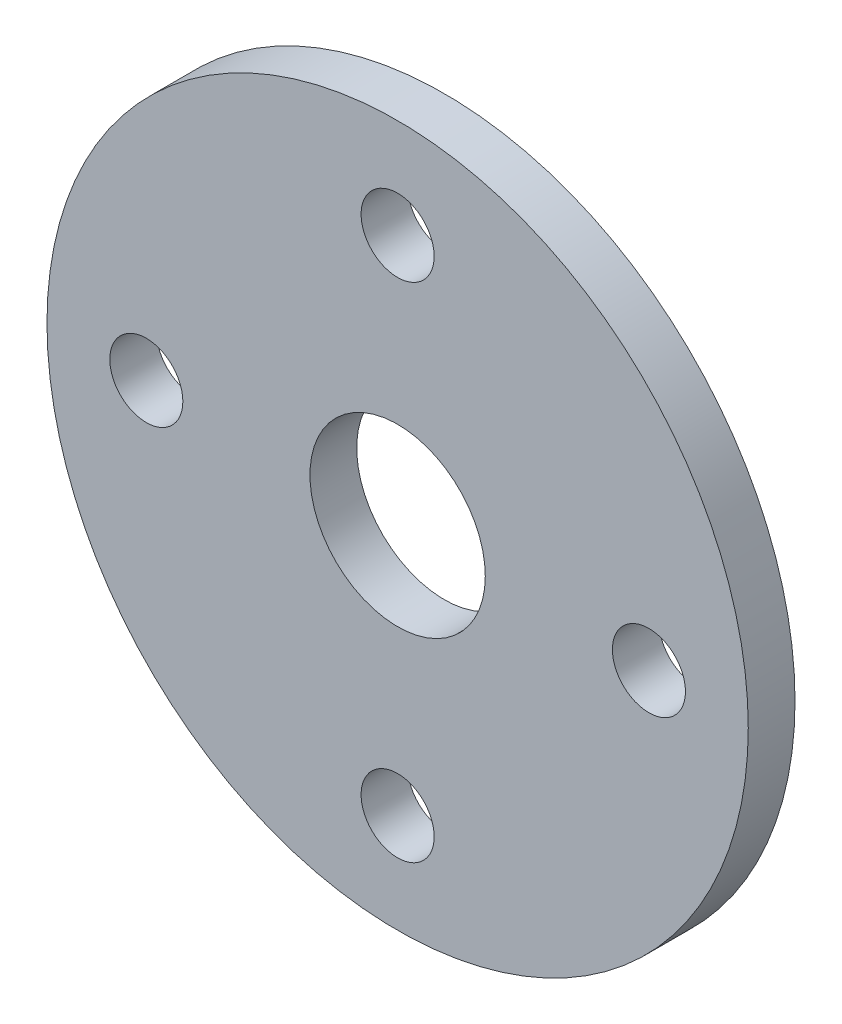
from build123d import *

# Parameters (mm, degrees)
ESQUISSE1_R        = 60
ESQUISSE1_R_2      = 15
ESQUISSE1_R_3      = 6.25
BOSS_EXTRU_1_DEPTH = 4


with BuildPart() as part:
    # Esquisse1 → Boss.-Extru.1 (new body, symmetric)
    with BuildSketch(Plane.XY):
        Circle(ESQUISSE1_R)
        Circle(ESQUISSE1_R_2, mode=Mode.SUBTRACT)
        with Locations((0, 43)):
            Circle(ESQUISSE1_R_3, mode=Mode.SUBTRACT)
        with Locations((-43, 0)):
            Circle(ESQUISSE1_R_3, mode=Mode.SUBTRACT)
        with Locations((0, -43)):
            Circle(ESQUISSE1_R_3, mode=Mode.SUBTRACT)
        with Locations((43, 0)):
            Circle(ESQUISSE1_R_3, mode=Mode.SUBTRACT)
    extrude(amount=BOSS_EXTRU_1_DEPTH, both=True)


solid = part.part
